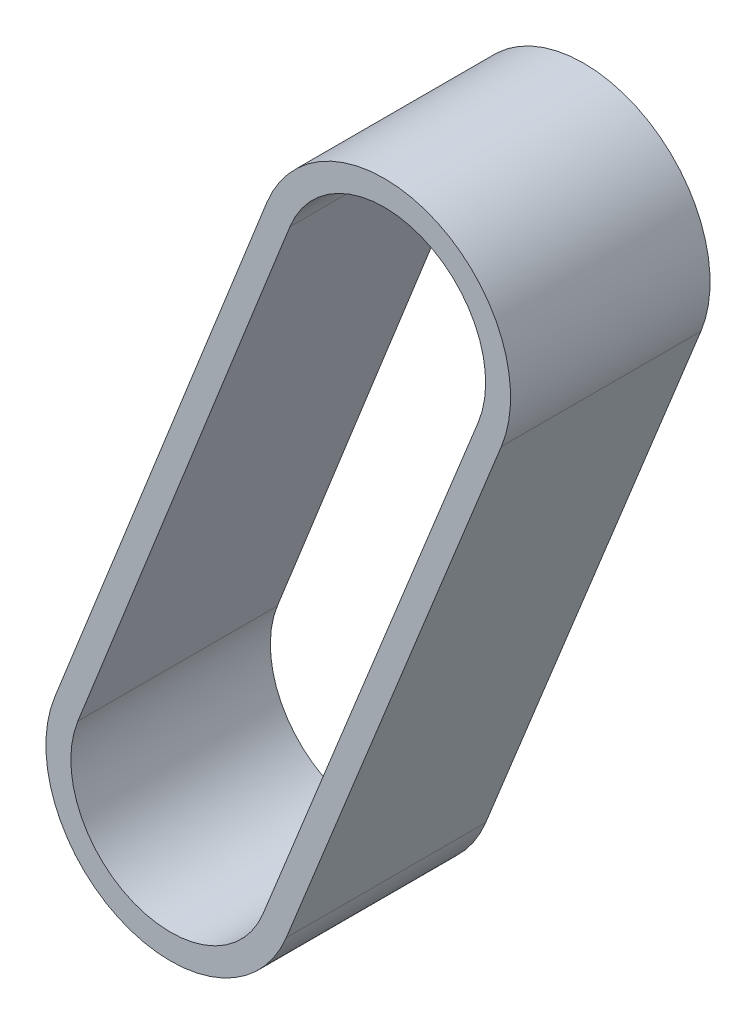
from build123d import *

# Parameters (mm, degrees)
SALIENTE_EXTRUIR1_DEPTH = 6


with BuildPart() as part:
    # Croquis3 → Saliente-Extruir1 (new body, symmetric)
    with BuildSketch(Plane.XY.offset(3)):
        with BuildLine():
            Line((-366.794500886, -8.207293434), (-353.852479494, 23.855275987))
            ThreePointArc((-353.852479494, 23.855275987), (-358.075670455, 33.755718434), (-367.963857344, 29.503911452))
            Line((-367.963857344, 29.503911452), (-380.720202712, -2.63298212))
            ThreePointArc((-380.720202712, -2.63298212), (-376.536458173, -12.362880034), (-366.794500886, -8.207293434))
        make_face()
        with BuildLine():
            Line((-366.569674973, 28.950507876), (-379.326020341, -3.186385696))
            ThreePointArc((-379.326020341, -3.186385696), (-375.979024711, -10.970304027), (-368.185458881, -7.645834747))
            Line((-368.185458881, -7.645834747), (-355.243437488, 24.416734674))
            ThreePointArc((-355.243437488, 24.416734674), (-358.633103918, 32.363142427), (-366.569674973, 28.950507876))
        make_face(mode=Mode.SUBTRACT)
    extrude(amount=SALIENTE_EXTRUIR1_DEPTH, both=True)


solid = part.part
